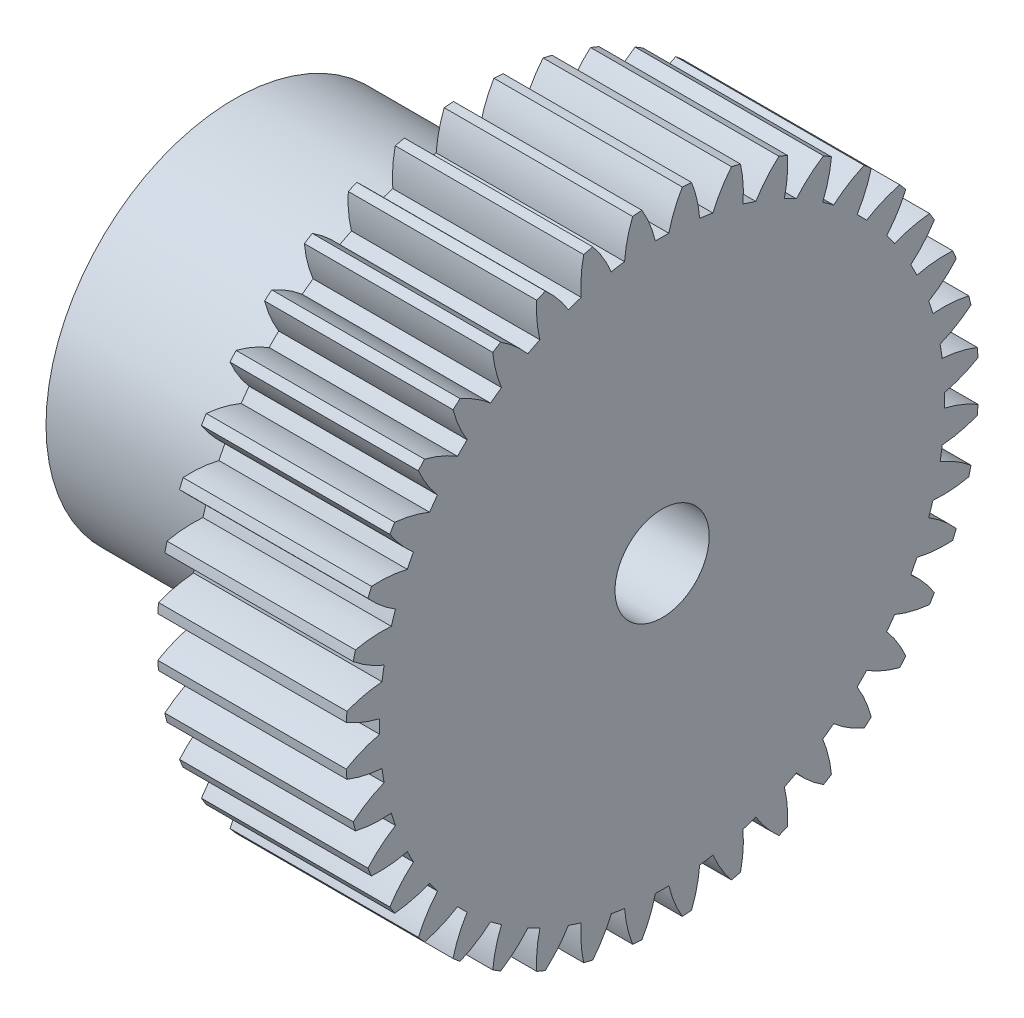
from build123d import *

# Parameters (mm, degrees)
BASPROSKE_W        = 10
BASPROSKE_H        = 16.8
TOOTHCUT_DEPTH     = 26.777509577
TEETHCUTS_COUNT    = 40
TEETHCUTS_ANGLE    = 351
HUBNEAONESKE_R     = 10
HUBNEARONE_DEPTH   = 12.7000508
BORSKE_R           = 2.5
BORE_DEPTH         = 27.897495554
BORE_DEPTH_BACK    = 27.897495554
SKETCH1_R          = 2.65
CUT_EXTRUDE1_DEPTH = 10


with BuildPart() as part:
    # BasProSke → Base-Revolve (revolve)
    with BuildSketch(Plane(origin=(0, 0, 0), x_dir=(1, 0, 0), z_dir=(0, 1, 0)), mode=Mode.PRIVATE) as base_revolve_sk:
        with Locations((5, 8.4)):
            Rectangle(BASPROSKE_W, BASPROSKE_H)
    revolve(base_revolve_sk.sketch.rotate(Axis((-10, 0, 0), (1, 0, 0)), 180), axis=Axis((-10, 0, 0), (1, 0, 0)))

    # TooCutSke → ToothCut (cut, through all)
    with BuildSketch(Plane(origin=(0, 0, 0), x_dir=(0, 0, -1), z_dir=(1, 0, 0))):
        with BuildLine():
            ThreePointArc((0.358234928, 14.994721362), (0, 14.999), (-0.358234928, 14.994721362))
            ThreePointArc((-0.358234928, 14.994721362), (-0.653764873, 15.920217236), (-1.085976921, 16.790316831))
            ThreePointArc((-1.085976921, 16.790316831), (0, 16.8254), (1.085976921, 16.790316831))
            ThreePointArc((1.085976921, 16.790316831), (0.653764873, 15.920217236), (0.358234928, 14.994721362))
        make_face()
    toothcut = extrude(amount=TOOTHCUT_DEPTH, mode=Mode.SUBTRACT)

    # TeethCuts: ToothCut ×40 about axis
    teethcuts_axis = Axis((-10, 0, 0), (1, 0, 0))
    for i in range(1, TEETHCUTS_COUNT):
        add(toothcut.rotate(teethcuts_axis, i * TEETHCUTS_ANGLE / (TEETHCUTS_COUNT - 1)), mode=Mode.SUBTRACT)

    # HubNeaOneSke → HubNearOne (add)
    with BuildSketch(Plane.ZY):
        with Locations(Location((0, 0, 0), (0, 0, 180))):
            Circle(HUBNEAONESKE_R)
    extrude(amount=HUBNEARONE_DEPTH)

    # BorSke → Bore (cut, two sides)
    with BuildSketch(Plane(origin=(0, 0, 0), x_dir=(0, 0, -1), z_dir=(1, 0, 0))) as bore_sk:
        Circle(BORSKE_R)
    extrude(amount=BORE_DEPTH, mode=Mode.SUBTRACT)
    extrude(bore_sk.sketch, amount=-BORE_DEPTH_BACK, mode=Mode.SUBTRACT)

    # Sketch1 → Cut-Extrude1 (cut)
    with BuildSketch(Plane(origin=(0, 0, 0), x_dir=(1, 0, 0), z_dir=(0, 1, 0))):
        with Locations(Location((-6.3500254, 0, 0), (0, 0, 289.370038246))):
            Circle(SKETCH1_R)
    extrude(amount=-CUT_EXTRUDE1_DEPTH, mode=Mode.SUBTRACT)


solid = part.part
